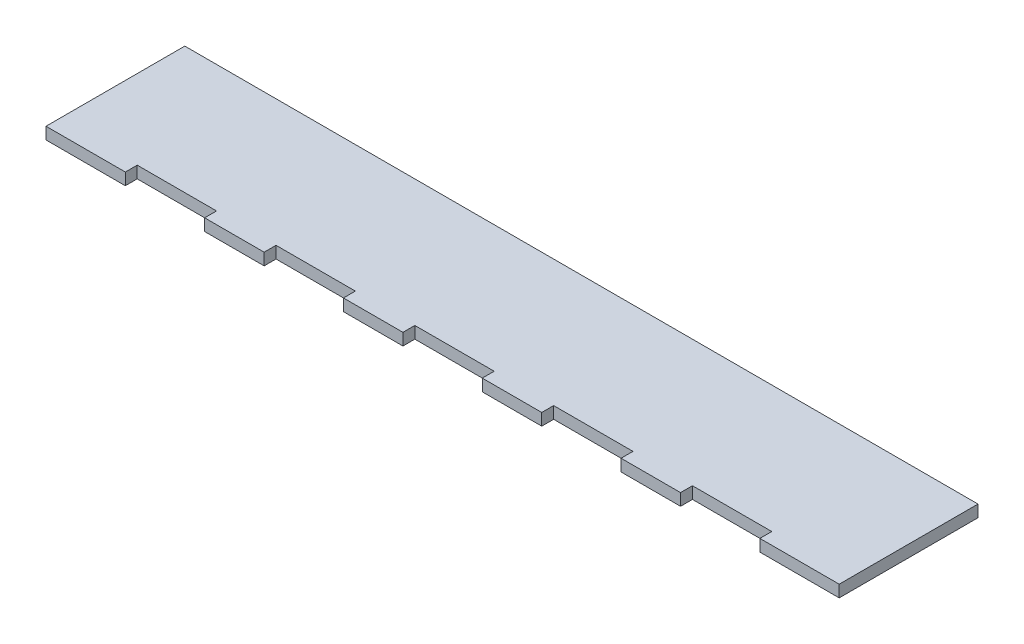
from build123d import *

# Parameters (mm, degrees)
BOSS_EXTRUDE1_DEPTH = 3


with BuildPart() as part:
    # Sketch1 → Boss-Extrude1 (new body)
    with BuildSketch(Plane(origin=(0, 0, 0), x_dir=(1, 0, 0), z_dir=(0, 1, 0))):
        Polygon((40, 0), (55, 0), (55, 3), (75, 3), (75, 0), (90, 0), (90, 3), (110, 3), (110, 0), (125, 0), (125, 3), (145, 3), (145, 0), (160, 0), (160, 3), (180, 3), (180, 0), (200, 0), (200, 35), (0, 35), (0, 0), (20, 0), (20, 3), (40, 3), align=None)
    extrude(amount=BOSS_EXTRUDE1_DEPTH)


solid = part.part
